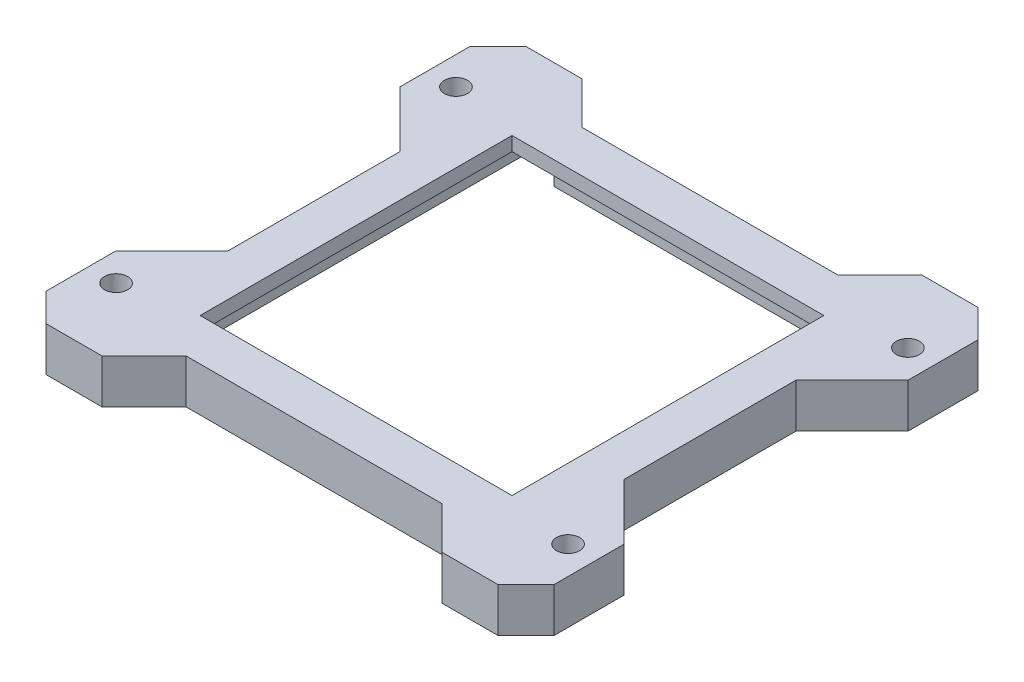
from build123d import *

# Parameters (mm, degrees)
SKETCH1_W           = 56.5
SKETCH1_H           = 56.5
SKETCH1_W_2         = 50.5
SKETCH1_H_2         = 50.5
SKETCH1_R           = 1.65
BOSS_EXTRUDE1_DEPTH = 8.6
SKETCH2_W           = 50.5
SKETCH2_H           = 50.5
SKETCH2_W_2         = 44.5
SKETCH2_H_2         = 44.5
BOSS_EXTRUDE2_DEPTH = 2
BOSS_EXTRUDE3_START = 6.6
SKETCH4_W           = 50.5
SKETCH4_H           = 50.5
SKETCH4_W_2         = 44.5
SKETCH4_H_2         = 44.5
BOSS_EXTRUDE3_DEPTH = 2
CUT_EXTRUDE1_START  = 2
SKETCH5_W           = 6
SKETCH5_H           = 17.961455198
CUT_EXTRUDE1_DEPTH  = 4.6
SKETCH6_W           = 87.3205389
SKETCH6_H           = 82.15723747
CUT_EXTRUDE2_DEPTH  = 2.3


with BuildPart() as part:
    # Sketch1 → Boss-Extrude1 (new body)
    with BuildSketch(Plane(origin=(0, 0, 0), x_dir=(1, 0, 0), z_dir=(0, 1, 0))):
        Rectangle(SKETCH1_W, SKETCH1_H)
        Rectangle(SKETCH1_W_2, SKETCH1_H_2, mode=Mode.SUBTRACT)
        Polygon((-28.25, -28.25), (-28.25, -12.25), (-36.25, -20.25), (-36.25, -30.25), (-32.25, -34.25), (-24.25, -34.25), (-18.25, -28.25), align=None)
        with Locations((-32.25, -24.25)):
            Circle(SKETCH1_R, mode=Mode.SUBTRACT)
        Polygon((28.25, -28.25), (18.25, -28.25), (24.25, -34.25), (32.25, -34.25), (36.25, -30.25), (36.25, -20.25), (28.25, -12.25), align=None)
        with Locations((32.25, -24.25)):
            Circle(SKETCH1_R, mode=Mode.SUBTRACT)
        Polygon((24.25, 34.25), (18.25, 28.25), (28.25, 28.25), (28.25, 12.25), (36.25, 20.25), (36.25, 30.25), (32.25, 34.25), align=None)
        with Locations((32.25, 24.25)):
            Circle(SKETCH1_R, mode=Mode.SUBTRACT)
        Polygon((-36.25, 20.25), (-28.25, 12.25), (-28.25, 28.25), (-18.25, 28.25), (-24.25, 34.25), (-32.25, 34.25), (-36.25, 30.25), align=None)
        with Locations((-32.25, 24.25)):
            Circle(SKETCH1_R, mode=Mode.SUBTRACT)
    extrude(amount=BOSS_EXTRUDE1_DEPTH)

    # Sketch2 → Boss-Extrude2 (add)
    with BuildSketch(Plane(origin=(0, 0, 0), x_dir=(1, 0, 0), z_dir=(0, 1, 0))):
        Rectangle(SKETCH2_W, SKETCH2_H)
        Rectangle(SKETCH2_W_2, SKETCH2_H_2, mode=Mode.SUBTRACT)
    extrude(amount=BOSS_EXTRUDE2_DEPTH)

    # Sketch4 → Boss-Extrude3 (add)
    with BuildSketch(Plane(origin=(0, 0, 0), x_dir=(1, 0, 0), z_dir=(0, 1, 0)).offset(BOSS_EXTRUDE3_START)):
        Rectangle(SKETCH4_W, SKETCH4_H)
        Rectangle(SKETCH4_W_2, SKETCH4_H_2, mode=Mode.SUBTRACT)
    extrude(amount=BOSS_EXTRUDE3_DEPTH)

    # Sketch5 → Cut-Extrude1 (cut)
    with BuildSketch(Plane(origin=(0, 0, 0), x_dir=(1, 0, 0), z_dir=(0, 1, 0)).offset(CUT_EXTRUDE1_START)):
        with Locations((-22.25, 28.869783692)):
            Rectangle(SKETCH5_W, SKETCH5_H)
        with Locations((22.25, 28.869783692)):
            Rectangle(SKETCH5_W, SKETCH5_H)
    extrude(amount=CUT_EXTRUDE1_DEPTH, mode=Mode.SUBTRACT)

    # Sketch6 → Cut-Extrude2 (cut)
    with BuildSketch(Plane.XZ):
        with Locations((1.898272585, -1.518618068)):
            Rectangle(SKETCH6_W, SKETCH6_H)
    extrude(amount=-CUT_EXTRUDE2_DEPTH, mode=Mode.SUBTRACT)


solid = part.part
